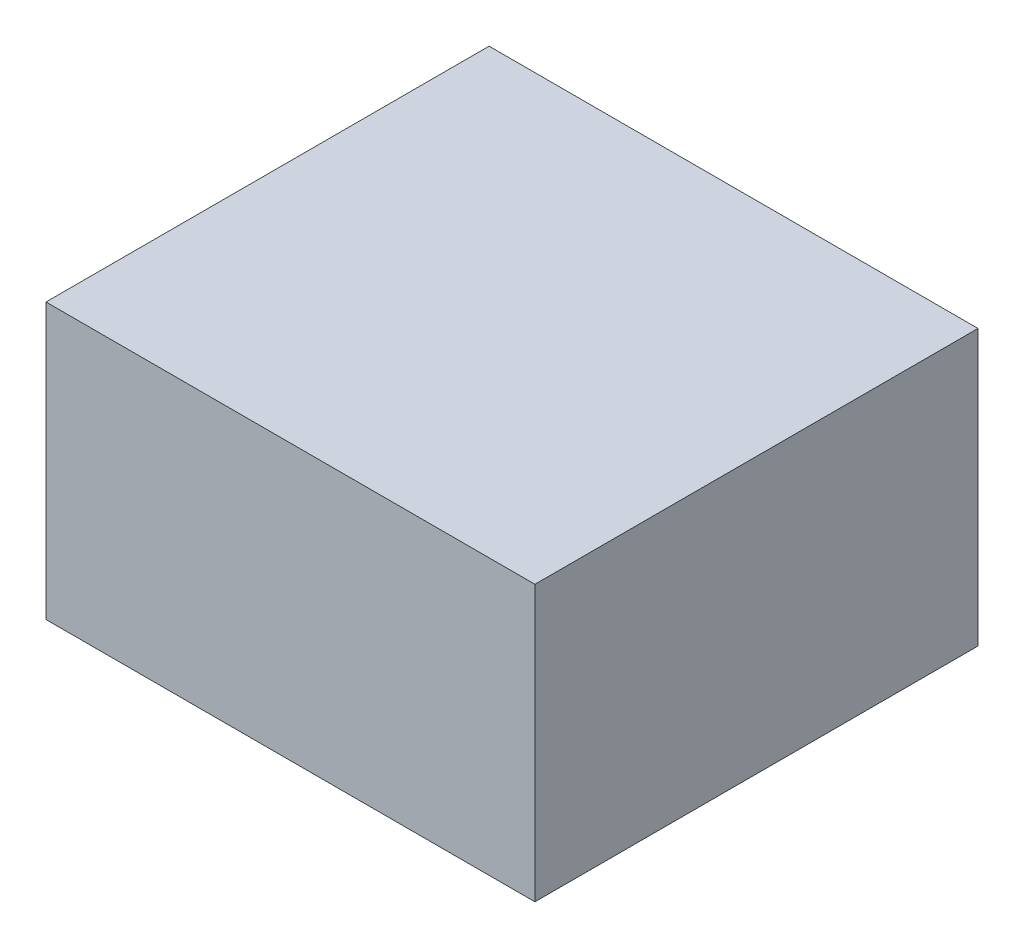
from build123d import *

# Parameters (mm, degrees)
SKETCH1_W           = 101.6
SKETCH1_H           = 92.075
BOSS_EXTRUDE1_DEPTH = 57.15


with BuildPart() as part:
    # Sketch1 → Boss-Extrude1 (new body)
    with BuildSketch(Plane(origin=(0, 0, 0), x_dir=(1, 0, 0), z_dir=(0, 1, 0))):
        Rectangle(SKETCH1_W, SKETCH1_H)
    extrude(amount=BOSS_EXTRUDE1_DEPTH)


solid = part.part
